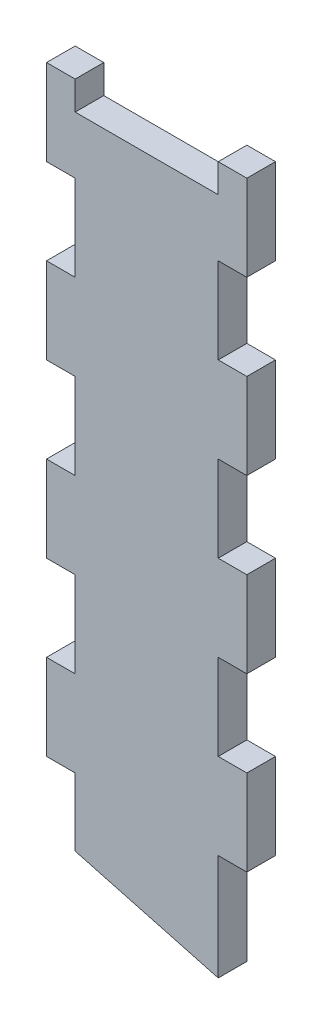
from build123d import *

# Parameters (mm, degrees)
BOSS_EXTRUDE1_DEPTH = 6


with BuildPart() as part:
    # Model → Boss-Extrude1 (new body)
    with BuildSketch(Plane.XY):
        Polygon((22.640815656, 12.986676319), (52.640815656, 4.948200546), (52.640815656, 27.179055183), (58.640815656, 27.179055183), (58.640815656, 45.179055183), (52.640815656, 45.179055183), (52.640815656, 63.179055183), (58.640815656, 63.179055183), (58.640815656, 81.179055183), (52.640815656, 81.179055183), (52.640815656, 99.179055183), (58.640815656, 99.179055183), (58.640815656, 117.179055183), (52.640815656, 117.179055183), (52.640815656, 135.179055183), (58.640815656, 135.179055183), (58.640815656, 153.179055183), (52.640815656, 153.179055183), (52.640815656, 147.179055183), (22.640815656, 147.179055183), (22.640815656, 153.179055183), (16.640815656, 153.179055183), (16.640815656, 135.179055183), (22.640815656, 135.179055183), (22.640815656, 117.179055183), (16.640815656, 117.179055183), (16.640815656, 99.179055183), (22.640815656, 99.179055183), (22.640815656, 81.179055183), (16.640815656, 81.179055183), (16.640815656, 63.179055183), (22.640815656, 63.179055183), (22.640815656, 45.179055183), (16.640815656, 45.179055183), (16.640815656, 27.179055183), (22.640815656, 27.179055183), align=None)
    extrude(amount=BOSS_EXTRUDE1_DEPTH)


solid = part.part
